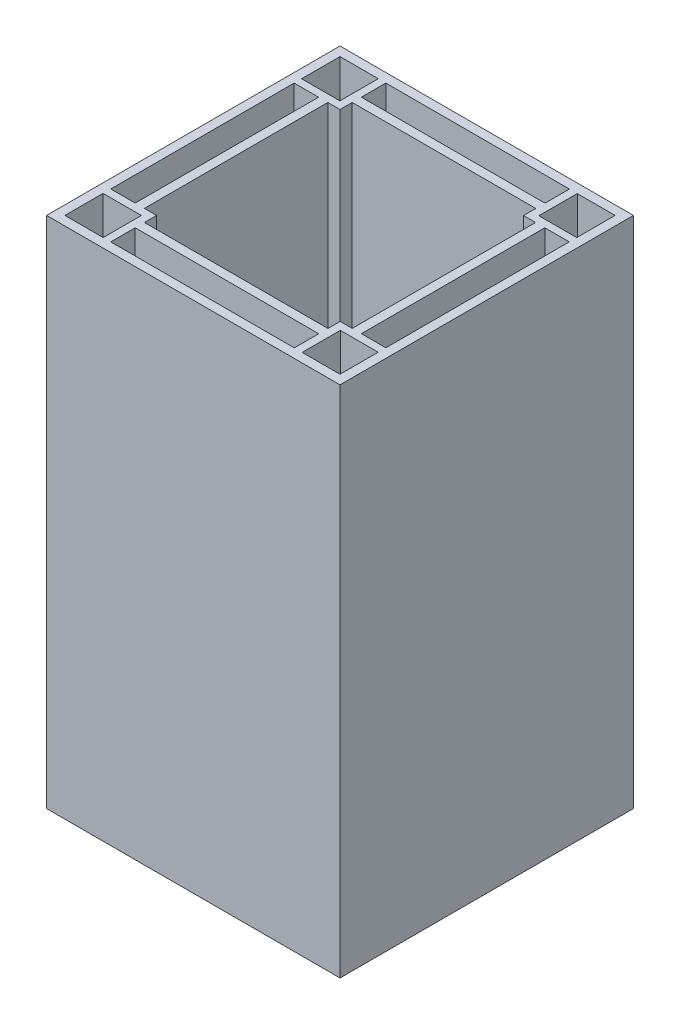
from build123d import *

# Parameters (mm, degrees)
SKETCH1_W               = 101.6
SKETCH1_H               = 203.2
BOSS_EXTRUDE1_DEPTH     = 101.6
SKETCH2_W               = 12.7
SKETCH2_H               = 12.7
SKETCH2_W_2             = 12.648057186
CUT_EXTRUDE1_DEPTH      = 203.2
SKETCH3_W               = 4.23418
SKETCH3_H               = 63.5
SKETCH3_W_2             = 63.551942814
SKETCH3_H_2             = 4.23418
SKETCH3_W_3             = 4.181475186
SKETCH3_W_4             = 8.466582
SKETCH3_H_3             = 8.46582
SKETCH3_W_5             = 8.46582
CUT_EXTRUDE2_DEPTH      = 200.025
SKETCH4_W               = 101.6
SKETCH4_H               = 25.341987408
CUT_EXTRUDE3_DEPTH      = 101.6
F_1_2_13_TAPPED_HOLE2_D = 10.71626
SKETCH7_W               = 13.255770889
SKETCH7_H               = 13.293622463
SKETCH7_W_2             = 13.104364594
SKETCH7_H_2             = 13.217919315
CUT_EXTRUDE4_DEPTH      = 190.5


with BuildPart() as part:
    # Sketch1 → Boss-Extrude1 (new body)
    with BuildSketch(Plane(origin=(0, 0, 0), x_dir=(0, 0, -1), z_dir=(1, 0, 0))):
        Rectangle(SKETCH1_W, SKETCH1_H)
    extrude(amount=BOSS_EXTRUDE1_DEPTH)

    # Sketch2 → Cut-Extrude1 (cut)
    with BuildSketch(Plane(origin=(0, 101.6, 0), x_dir=(1, 0, 0), z_dir=(0, 1, 0))):
        with Locations((9.525, 41.275)):
            Rectangle(SKETCH2_W, SKETCH2_H)
        with Locations((9.525, -41.275)):
            Rectangle(SKETCH2_W, SKETCH2_H)
        with Locations((92.100971407, -41.275)):
            Rectangle(SKETCH2_W_2, SKETCH2_H)
        with Locations((92.100971407, 41.275)):
            Rectangle(SKETCH2_W_2, SKETCH2_H)
    extrude(amount=-CUT_EXTRUDE1_DEPTH, mode=Mode.SUBTRACT)

    # Sketch3 → Cut-Extrude2 (cut)
    with BuildSketch(Plane(origin=(0, 101.6, 0), x_dir=(1, 0, 0), z_dir=(0, 1, 0))):
        with Locations((16.93291, 0)):
            Rectangle(SKETCH3_W, SKETCH3_H)
        with Locations((50.825971407, 0)):
            Rectangle(SKETCH3_W_2, SKETCH3_H)
        with Locations((50.825971407, 33.86709)):
            Rectangle(SKETCH3_W_2, SKETCH3_H_2)
        with Locations((84.692680407, 0)):
            Rectangle(SKETCH3_W_3, SKETCH3_H)
        with Locations((94.191709, 0)):
            Rectangle(SKETCH3_W_4, SKETCH3_H)
        with Locations((50.825971407, 43.39209)):
            Rectangle(SKETCH3_W_2, SKETCH3_H_3)
        with Locations((7.40791, 0)):
            Rectangle(SKETCH3_W_5, SKETCH3_H)
        with Locations((50.825971407, -43.39209)):
            Rectangle(SKETCH3_W_2, SKETCH3_H_3)
        with Locations((50.825971407, -33.86709)):
            Rectangle(SKETCH3_W_2, SKETCH3_H_2)
    extrude(amount=-CUT_EXTRUDE2_DEPTH, mode=Mode.SUBTRACT)

    # Sketch4 → Cut-Extrude3 (cut)
    with BuildSketch(Plane(origin=(101.6, 0, 0), x_dir=(0, 0, -1), z_dir=(1, 0, 0))):
        with Locations((0, 88.929006296)):
            Rectangle(SKETCH4_W, SKETCH4_H)
    extrude(amount=-CUT_EXTRUDE3_DEPTH, mode=Mode.SUBTRACT)

    # 1/2-13 Tapped Hole2 (through all)
    with Locations(Plane(origin=(50.825971407, -98.425, 0), x_dir=(0, 0, 1), z_dir=(0, 1, 0))):
        with Locations((0, 0)):
            Hole(F_1_2_13_TAPPED_HOLE2_D / 2)

    # Sketch7 → Cut-Extrude4 (cut)
    with BuildSketch(Plane(origin=(0, 76.258012592, 0), x_dir=(1, 0, 0), z_dir=(0, 1, 0))):
        with Locations((9.802885445, 40.978188769)):
            Rectangle(SKETCH7_W, SKETCH7_H)
        with Locations((91.872817703, 40.978188769)):
            Rectangle(SKETCH7_W_2, SKETCH7_H)
        with Locations((91.872817703, -41.016040343)):
            Rectangle(SKETCH7_W_2, SKETCH7_H_2)
        with Locations((9.802885445, -41.016040343)):
            Rectangle(SKETCH7_W, SKETCH7_H_2)
    extrude(amount=-CUT_EXTRUDE4_DEPTH, mode=Mode.SUBTRACT)


solid = part.part
